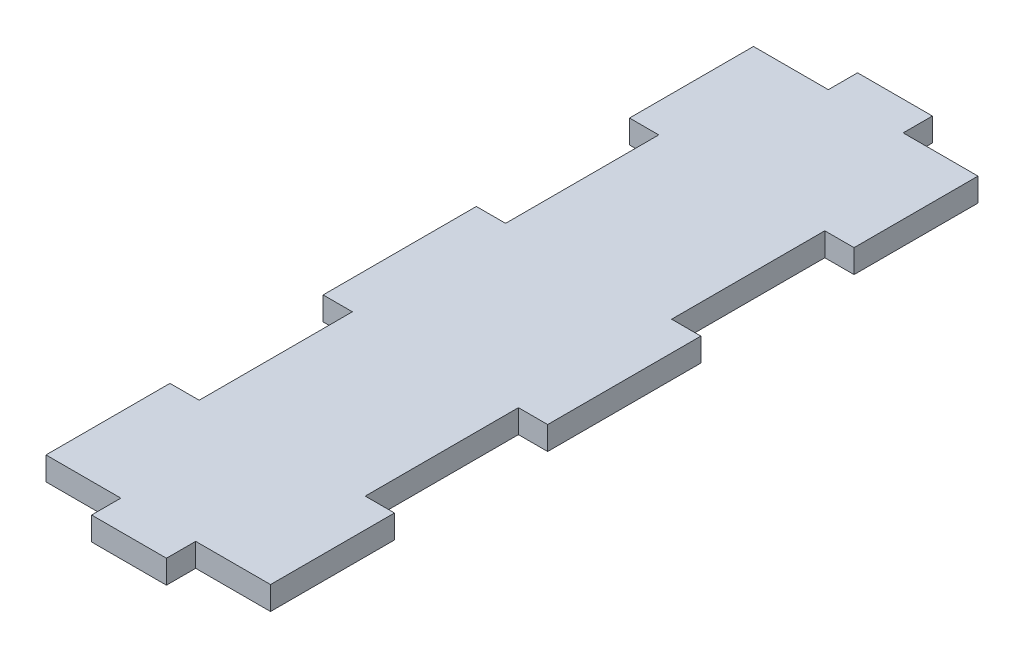
from build123d import *

# Parameters (mm, degrees)
SKETCH1_W           = 24.384
SKETCH1_H           = 83.185
BOSS_EXTRUDE1_DEPTH = 2.54
SKETCH2_W           = 3.175
SKETCH2_H           = 16.637
CUT_EXTRUDE1_DEPTH  = 2.54
LPATTERN1_COUNT     = 2
LPATTERN1_PITCH     = 33.274
SKETCH3_W           = 8.128
SKETCH3_H           = 3.175
CUT_EXTRUDE5_DEPTH  = 3.175
LPATTERN3_COUNT     = 2
LPATTERN3_PITCH     = 16.256


with BuildPart() as part:
    # Sketch1 → Boss-Extrude1 (new body)
    with BuildSketch(Plane(origin=(0, 0, 0), x_dir=(1, 0, 0), z_dir=(0, 1, 0))):
        Rectangle(SKETCH1_W, SKETCH1_H)
    extrude(amount=BOSS_EXTRUDE1_DEPTH)

    # Sketch2 → Cut-Extrude1 (cut)
    with BuildSketch(Plane(origin=(0, 2.54, 0), x_dir=(1, 0, 0), z_dir=(0, 1, 0))):
        with Locations((-10.6045, 16.637)):
            Rectangle(SKETCH2_W, SKETCH2_H)
        with Locations((10.6045, 16.637)):
            Rectangle(SKETCH2_W, SKETCH2_H)
    cut_extrude1 = extrude(amount=-CUT_EXTRUDE1_DEPTH, mode=Mode.SUBTRACT)

    # LPattern1: Cut-Extrude1 ×2
    with Locations(*[(0, 0, i * LPATTERN1_PITCH) for i in range(1, LPATTERN1_COUNT)]):
        add(cut_extrude1, mode=Mode.SUBTRACT)

    # Sketch3 → Cut-Extrude5 (cut)
    with BuildSketch(Plane(origin=(0, 2.54, 0), x_dir=(1, 0, 0), z_dir=(0, 1, 0))):
        with Locations((8.128, 40.005)):
            Rectangle(SKETCH3_W, SKETCH3_H)
        with Locations((8.128, -40.005)):
            Rectangle(SKETCH3_W, SKETCH3_H)
    cut_extrude5 = extrude(amount=-CUT_EXTRUDE5_DEPTH, mode=Mode.SUBTRACT)

    # LPattern3: Cut-Extrude5 ×2
    with Locations(*[(-i * LPATTERN3_PITCH, 0, 0) for i in range(1, LPATTERN3_COUNT)]):
        add(cut_extrude5, mode=Mode.SUBTRACT)


solid = part.part
